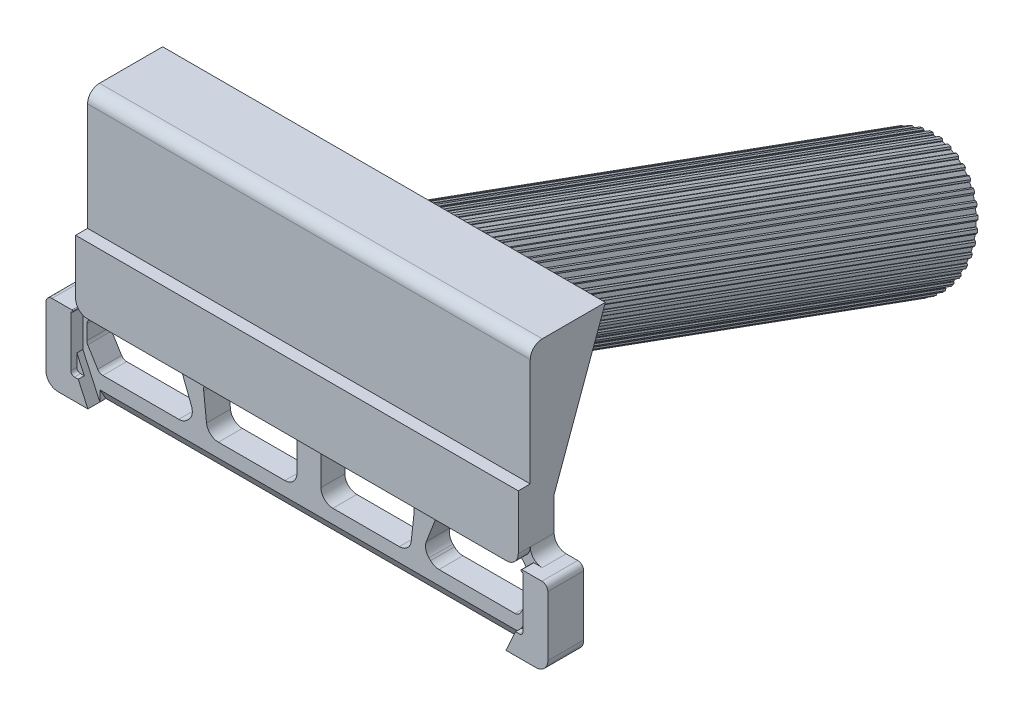
from build123d import *

# Parameters (mm, degrees)
BOSS_EXTRUDE3_DEPTH              = 2
BOSS_EXTRUDE4_DEPTH              = 1
PILL_EXTRUDE_DEPTH               = 1
BOSS_EXTRUDE7_DEPTH              = 1
CUT_EXTRUDE2_DEPTH               = 0.5
BOSS_EXTRUDE11_REACH             = 22.964
BOSS_EXTRUDE11_DIRECTION_2_REACH = 22.964
SKETCH28_R                       = 5
SKETCH28_R_2                     = 2.5
BOSS_EXTRUDE12_DEPTH             = 50
BOSS_EXTRUDE13_DEPTH             = 45
CHAMFER3_SIZE                    = 0.1
CIRPATTERN1_COUNT                = 40
CHAMFER3_OF_CIRPATTERN1_SIZE     = 0.1
CUT_EXTRUDE11_DEPTH              = 17.464143
CUT_EXTRUDE11_DEPTH_BACK         = 17.464143


with BuildPart() as part:
    # base plate → Boss-Extrude3 (new body)
    with BuildSketch(Plane.XY):
        with BuildLine():
            Line((19.493715087, 6.5), (20.464143237, 6.5))
            ThreePointArc((20.464143237, 6.5), (20.817696627, 6.353553391), (20.964143237, 6))
            Line((20.964143237, 6), (20.964143237, 1))
            ThreePointArc((20.964143237, 1), (20.671250018, 0.292893219), (19.964143237, 0))
            Line((19.964143237, 0), (-19.964143237, 0))
            ThreePointArc((-19.964143237, 0), (-20.671250018, 0.292893219), (-20.964143237, 1))
            Line((-20.964143237, 1), (-20.964143237, 6))
            ThreePointArc((-20.964143237, 6), (-20.817696627, 6.353553391), (-20.464143237, 6.5))
            Line((-20.464143237, 6.5), (-19.493715087, 6.5))
            ThreePointArc((-19.493715087, 6.5), (-18.786608306, 6.792893219), (-18.493715087, 7.5))
            Line((-18.493715087, 7.5), (-18.493715087, 12.054490319))
            Line((-18.493715087, 12.054490319), (18.493715087, 12.054490319))
            Line((18.493715087, 12.054490319), (18.493715087, 7.5))
            ThreePointArc((18.493715087, 7.5), (18.786608306, 6.792893219), (19.493715087, 6.5))
        make_face()
        with BuildLine():
            Line((2.006153053, 6.5), (7.956153053, 6.5))
            Line((7.956153053, 6.5), (8.501671849, 5.954481204))
            ThreePointArc((8.501671849, 5.954481204), (8.737625541, 5.579995745), (8.788820951, 5.140345277))
            Line((8.788820951, 5.140345277), (8.55227912, 2.942970854))
            ThreePointArc((8.55227912, 2.942970854), (8.226218887, 2.3060144), (7.558023237, 2.05))
            Line((7.558023237, 2.05), (2.006153053, 2.05))
            ThreePointArc((2.006153053, 2.05), (1.299046272, 2.342893219), (1.006153053, 3.05))
            Line((1.006153053, 3.05), (1.006153053, 5.5))
            ThreePointArc((1.006153053, 5.5), (1.299046272, 6.207106781), (2.006153053, 6.5))
        make_face(mode=Mode.SUBTRACT)
        with BuildLine():
            Line((18.011095885, 6.057365635), (18.465133578, 5.381018621))
            ThreePointArc((18.465133578, 5.381018621), (18.528313072, 5.247995014), (18.55, 5.102335803))
            Line((18.55, 5.102335803), (18.55, 3.895789668))
            ThreePointArc((18.55, 3.895789668), (18.531183389, 3.759912717), (18.476149817, 3.634262741))
            Line((18.476149817, 3.634262741), (17.650242536, 2.288473073))
            ThreePointArc((17.650242536, 2.288473073), (17.468261244, 2.113672449), (17.224092719, 2.05))
            Line((17.224092719, 2.05), (10.870366616, 2.05))
            ThreePointArc((10.870366616, 2.05), (10.487683183, 2.126120467), (10.163259834, 2.342893219))
            Line((10.163259834, 2.342893219), (10.03330995, 2.472843103))
            ThreePointArc((10.03330995, 2.472843103), (9.761890711, 2.973826553), (9.808152704, 3.541728524))
            Line((9.808152704, 3.541728524), (10.708481955, 5.861778639))
            ThreePointArc((10.708481955, 5.861778639), (11.075847159, 6.325160178), (11.640745982, 6.5))
            Line((11.640745982, 6.5), (17.18082873, 6.5))
            ThreePointArc((17.18082873, 6.5), (17.651272332, 6.382430064), (18.011095885, 6.057365635))
        make_face(mode=Mode.SUBTRACT)
        with BuildLine():
            Line((-9.808152704, 3.541728524), (-10.708481955, 5.861778639))
            ThreePointArc((-10.708481955, 5.861778639), (-11.075847159, 6.325160178), (-11.640745982, 6.5))
            Line((-11.640745982, 6.5), (-17.18082873, 6.5))
            ThreePointArc((-17.18082873, 6.5), (-17.651272332, 6.382430064), (-18.011095885, 6.057365635))
            Line((-18.011095885, 6.057365635), (-18.465133578, 5.381018621))
            ThreePointArc((-18.465133578, 5.381018621), (-18.528313072, 5.247995014), (-18.55, 5.102335803))
            Line((-18.55, 5.102335803), (-18.55, 3.895789668))
            ThreePointArc((-18.55, 3.895789668), (-18.531183389, 3.759912717), (-18.476149817, 3.634262741))
            Line((-18.476149817, 3.634262741), (-17.650242536, 2.288473073))
            ThreePointArc((-17.650242536, 2.288473073), (-17.468261244, 2.113672449), (-17.224092719, 2.05))
            Line((-17.224092719, 2.05), (-10.870366616, 2.05))
            ThreePointArc((-10.870366616, 2.05), (-10.487683183, 2.126120467), (-10.163259834, 2.342893219))
            Line((-10.163259834, 2.342893219), (-10.03330995, 2.472843103))
            ThreePointArc((-10.03330995, 2.472843103), (-9.761890711, 2.973826553), (-9.808152704, 3.541728524))
        make_face(mode=Mode.SUBTRACT)
        with BuildLine():
            Line((-8.788820951, 5.140345277), (-8.55227912, 2.942970854))
            ThreePointArc((-8.55227912, 2.942970854), (-8.226218887, 2.3060144), (-7.558023237, 2.05))
            Line((-7.558023237, 2.05), (-2.006153053, 2.05))
            ThreePointArc((-2.006153053, 2.05), (-1.299046272, 2.342893219), (-1.006153053, 3.05))
            Line((-1.006153053, 3.05), (-1.006153053, 5.5))
            ThreePointArc((-1.006153053, 5.5), (-1.299046272, 6.207106781), (-2.006153053, 6.5))
            Line((-2.006153053, 6.5), (-7.956153053, 6.5))
            Line((-7.956153053, 6.5), (-8.501671849, 5.954481204))
            ThreePointArc((-8.501671849, 5.954481204), (-8.737625541, 5.579995745), (-8.788820951, 5.140345277))
        make_face(mode=Mode.SUBTRACT)
    extrude(amount=BOSS_EXTRUDE3_DEPTH)

    # Sketch3 → Boss-Extrude4 (add)
    with BuildSketch(Plane.XY.offset(2)):
        with BuildLine():
            Line((-18.493715087, 12.054490319), (18.493715087, 12.054490319))
            Line((18.493715087, 12.054490319), (18.493715087, 7.5))
            ThreePointArc((18.493715087, 7.5), (18.200821868, 6.792893219), (17.493715087, 6.5))
            Line((17.493715087, 6.5), (-17.493715087, 6.5))
            ThreePointArc((-17.493715087, 6.5), (-18.200821868, 6.792893219), (-18.493715087, 7.5))
            Line((-18.493715087, 7.5), (-18.493715087, 12.054490319))
        make_face()
    extrude(amount=BOSS_EXTRUDE4_DEPTH)

    # pill → pill extrude (add)
    with BuildSketch(Plane.XY.offset(3)):
        with BuildLine():
            Line((18.884533801, 6), (20.964143237, 6))
            ThreePointArc((20.964143237, 6), (20.817696627, 6.353553391), (20.464143237, 6.5))
            Line((20.464143237, 6.5), (18.798100713, 6.5))
            ThreePointArc((18.798100713, 6.5), (18.748603238, 6.479497475), (18.728100713, 6.43))
            Line((18.728100713, 6.43), (18.728100713, 6.409629257))
            ThreePointArc((18.728100713, 6.409629257), (18.748603238, 6.360131783), (18.798100713, 6.339629257))
            Line((18.798100713, 6.339629257), (18.814533801, 6.339629257))
            ThreePointArc((18.814533801, 6.339629257), (18.864031276, 6.319126732), (18.884533801, 6.269629257))
            Line((18.884533801, 6.269629257), (18.884533801, 6))
        make_face()
        with BuildLine():
            Line((-20.964143237, 6), (-18.884533801, 6))
            Line((-18.884533801, 6), (-18.884533801, 6.269629257))
            ThreePointArc((-18.884533801, 6.269629257), (-18.864031276, 6.319126732), (-18.814533801, 6.339629257))
            Line((-18.814533801, 6.339629257), (-18.798100713, 6.339629257))
            ThreePointArc((-18.798100713, 6.339629257), (-18.748603238, 6.360131783), (-18.728100713, 6.409629257))
            Line((-18.728100713, 6.409629257), (-18.728100713, 6.43))
            ThreePointArc((-18.728100713, 6.43), (-18.748603238, 6.479497475), (-18.798100713, 6.5))
            Line((-18.798100713, 6.5), (-20.464143237, 6.5))
            ThreePointArc((-20.464143237, 6.5), (-20.817696627, 6.353553391), (-20.964143237, 6))
        make_face()
    extrude(amount=-PILL_EXTRUDE_DEPTH)

    # pods → Boss-Extrude7 (add)
    with BuildSketch(Plane.XY.offset(2)):
        with BuildLine():
            Line((20.964143237, 1), (20.964143237, 6))
            Line((20.964143237, 6), (18.884533801, 6))
            Line((18.884533801, 6), (18.884533801, 3.1))
            Line((18.884533801, 3.1), (17.464143237, 0))
            Line((17.464143237, 0), (19.964143237, 0))
            ThreePointArc((19.964143237, 0), (20.671250018, 0.292893219), (20.964143237, 1))
        make_face()
        with BuildLine():
            Line((-17.464143237, 0), (-18.884533801, 3.1))
            Line((-18.884533801, 3.1), (-18.884533801, 6))
            Line((-18.884533801, 6), (-20.964143237, 6))
            Line((-20.964143237, 6), (-20.964143237, 1))
            ThreePointArc((-20.964143237, 1), (-20.671250018, 0.292893219), (-19.964143237, 0))
            Line((-19.964143237, 0), (-17.464143237, 0))
        make_face()
    extrude(amount=BOSS_EXTRUDE7_DEPTH)

    # Sketch7 → Cut-Extrude2 (cut)
    with BuildSketch(Plane.XY.offset(3)):
        with BuildLine():
            Line((-18.584533801, 1.75), (18.584533801, 1.75))
            ThreePointArc((18.584533801, 1.75), (18.796665835, 1.837867966), (18.884533801, 2.05))
            Line((18.884533801, 2.05), (18.884533801, 6.269629257))
            Line((18.884533801, 6.269629257), (-18.884533801, 6.269629257))
            Line((-18.884533801, 6.269629257), (-18.884533801, 2.05))
            ThreePointArc((-18.884533801, 2.05), (-18.796665835, 1.837867966), (-18.584533801, 1.75))
        make_face()
    extrude(amount=-CUT_EXTRUDE2_DEPTH, mode=Mode.SUBTRACT)

    # Boss-Extrude11: up to this face of the body (flat: up to its plane)
    boss_extrude11_end = Plane(part.part.faces().sort_by_distance((18.493715087, 9.77724516, 1.5))[0])
    # Sketch12 → Boss-Extrude11 (add, up to the picked face)
    with BuildSketch(Plane(origin=(0, 0, 0), x_dir=(0, 0, -1), z_dir=(1, 0, 0)), mode=Mode.PRIVATE) as boss_extrude11_sk1:
        with BuildLine():
            Line((-2, 12.054490319), (-2, 21.054490319))
            ThreePointArc((-2, 21.054490319), (-1.707106781, 21.7615971), (-1, 22.054490319))
            Line((-1, 22.054490319), (4.275888282, 22.054490319))
            Line((4.275888282, 22.054490319), (0, 10.306583817))
            Line((0, 10.306583817), (-2, 12.054490319))
        make_face()
    boss_extrude11_tool1 = split(extrude(boss_extrude11_sk1.sketch, amount=BOSS_EXTRUDE11_REACH, mode=Mode.PRIVATE), bisect_by=boss_extrude11_end, keep=Keep.BOTH, mode=Mode.PRIVATE)
    add(boss_extrude11_tool1.solids().sort_by_distance((0, 17.406989, -0.321851))[0])

    # Boss-Extrude11 direction 2: up to this face of the body (flat: up to its plane)
    boss_extrude11_direction_2_end = Plane(part.part.faces().sort_by_distance((-18.493715087, 9.77724516, 1.5))[0])
    # Sketch12 → Boss-Extrude11 direction 2 (add, up to the picked face)
    with BuildSketch(Plane(origin=(0, 0, 0), x_dir=(0, 0, -1), z_dir=(1, 0, 0)), mode=Mode.PRIVATE) as boss_extrude11_direction_2_sk1:
        with BuildLine():
            Line((-2, 12.054490319), (-2, 21.054490319))
            ThreePointArc((-2, 21.054490319), (-1.707106781, 21.7615971), (-1, 22.054490319))
            Line((-1, 22.054490319), (4.275888282, 22.054490319))
            Line((4.275888282, 22.054490319), (0, 10.306583817))
            Line((0, 10.306583817), (-2, 12.054490319))
        make_face()
    boss_extrude11_direction_2_tool1 = split(extrude(boss_extrude11_direction_2_sk1.sketch, amount=-BOSS_EXTRUDE11_DIRECTION_2_REACH, mode=Mode.PRIVATE), bisect_by=boss_extrude11_direction_2_end, keep=Keep.BOTH, mode=Mode.PRIVATE)
    add(boss_extrude11_direction_2_tool1.solids().sort_by_distance((0, 17.406989, -0.321851))[0])

    # Sketch28 → Boss-Extrude12 (add)
    with BuildSketch(Plane(origin=(0, 1.205641278, 3.312472188), x_dir=(-1, 0, 0), z_dir=(0, -0.342020143, -0.939692621))):
        with Locations((0, 14)):
            Circle(SKETCH28_R)
        with Locations((0, 14)):
            Circle(SKETCH28_R_2, mode=Mode.SUBTRACT)
    extrude(amount=BOSS_EXTRUDE12_DEPTH)

    # Sketch30 → Boss-Extrude13 (add)
    with BuildSketch(Plane(origin=(0, -15.895365888, -43.672158852), x_dir=(-1, 0, 0), z_dir=(0, -0.342020143, -0.939692621))):
        with BuildLine():
            ThreePointArc((5, 14), (4.995241108, 13.781903063), (4.98097349, 13.564221286))
            Line((4.98097349, 13.564221286), (5.130402695, 13.551147925))
            ThreePointArc((5.130402695, 13.551147925), (5.145098341, 13.775360155), (5.15, 14))
            Line((5.15, 14), (5, 14))
        make_face()
    boss_extrude13 = extrude(amount=-BOSS_EXTRUDE13_DEPTH)

    # Chamfer3
    chamfer3_edges = [part.edges().sort_by_distance(p)[0] for p in [
        (-5.130402695, 4.534001045, -27.163840439),
        (-5.15, 4.955784028, -27.31735689),
    ]]
    chamfer(chamfer3_edges, length=CHAMFER3_SIZE)

    # CirPattern1: Boss-Extrude13 ×40 about axis
    cirpattern1_axis = Axis((0, 13.155696691, -4.788282007), (0, -0.342020143, -0.939692621))
    for i in range(1, CIRPATTERN1_COUNT):
        add(boss_extrude13.rotate(cirpattern1_axis, i * 360 / CIRPATTERN1_COUNT))

    # Chamfer3 of CirPattern1
    chamfer3_of_cirpattern1_edges = [part.edges().sort_by_distance(p)[0] for p in [
        (-5.137454859, 5.293364692, -27.440226204),
        (-5.086594954, 5.712835637, -27.592901142),
        (-5.018005834, 6.044415984, -27.713586518),
        (-4.897941059, 6.451246123, -27.861660579),
        (-4.774996851, 6.768661543, -27.977190344),
        (-4.5886836, 7.152833369, -28.117017454),
        (-4.414411599, 7.448268042, -28.224546881),
        (-4.166437521, 7.800321968, -28.352684031),
        (-3.945128882, 8.066501312, -28.449565389),
        (-3.641599923, 8.377768603, -28.562857418),
        (-3.378703999, 8.608138398, -28.646705166),
        (-3.027094049, 8.870954621, -28.742362449),
        (-2.729084211, 9.059842399, -28.811111977),
        (-2.338051074, 9.267736145, -28.886779113),
        (-2.012265312, 9.410490861, -28.93873758),
        (-1.591437521, 9.558343098, -28.992551393),
        (-1.245897762, 9.651449658, -29.02643941),
        (-0.805637495, 9.735619771, -29.057074826),
        (-0.448852075, 9.776785582, -29.072057956),
        (0, 9.795201025, -29.078760629),
        (0.35924584, 9.783412448, -29.074469938),
        (0.805637495, 9.735619771, -29.057074826),
        (1.15849793, 9.671167081, -29.033615965),
        (1.591437521, 9.558343098, -28.992551393),
        (1.929223956, 9.442813333, -28.950501998),
        (2.338051074, 9.267736145, -28.886779113),
        (2.652446086, 9.103974032, -28.827174578),
        (3.027094049, 8.870954621, -28.742362449),
        (3.31035619, 8.662992526, -28.666670436),
        (3.641599923, 8.377768603, -28.562857418),
        (3.886754338, 8.130727244, -28.472941717),
        (4.166437521, 7.800321968, -28.352684031),
        (4.367447695, 7.520284322, -28.250758663),
        (4.5886836, 7.152833369, -28.117017454),
        (4.740599995, 6.846694892, -28.005592161),
        (4.897941059, 6.451246123, -27.861660579),
        (4.99702299, 6.126544961, -27.743479022),
        (5.086594954, 5.712835637, -27.592901142),
        (5.130402695, 5.377567011, -27.470873342),
        (5.15, 4.955784028, -27.31735689),
        (5.137454859, 4.618203363, -27.194487577),
        (5.086594954, 4.198732419, -27.041812639),
        (5.018005834, 3.867152072, -26.921127262),
        (4.897941059, 3.460321933, -26.773053201),
        (4.774996851, 3.142906512, -26.657523436),
        (4.5886836, 2.758734687, -26.517696327),
        (4.414411599, 2.463300014, -26.4101669),
        (4.166437521, 2.111246087, -26.28202975),
        (3.945128882, 1.845066744, -26.185148392),
        (3.641599923, 1.533799452, -26.071856363),
        (3.378703999, 1.303429657, -25.988008615),
        (3.027094049, 1.040613434, -25.892351332),
        (2.729084211, 0.851725657, -25.823601804),
        (2.338051074, 0.64383191, -25.747934668),
        (2.012265312, 0.501077194, -25.695976201),
        (1.591437521, 0.353224958, -25.642162387),
        (1.245897762, 0.260118398, -25.608274371),
        (0.805637495, 0.175948284, -25.577638955),
        (0.448852075, 0.134782473, -25.562655825),
        (0, 0.116367031, -25.555953152),
        (-0.35924584, 0.128155607, -25.560243843),
        (-0.805637495, 0.175948284, -25.577638955),
        (-1.15849793, 0.240400975, -25.601097816),
        (-1.591437521, 0.353224958, -25.642162387),
        (-1.929223956, 0.468754723, -25.684211783),
        (-2.338051074, 0.64383191, -25.747934668),
        (-2.652446086, 0.807594023, -25.807539203),
        (-3.027094049, 1.040613434, -25.892351332),
        (-3.31035619, 1.248575529, -25.968043345),
        (-3.641599923, 1.533799452, -26.071856363),
        (-3.886754338, 1.780840812, -26.161772064),
        (-4.166437521, 2.111246087, -26.28202975),
        (-4.367447695, 2.391283733, -26.383955118),
        (-4.5886836, 2.758734687, -26.517696327),
        (-4.740599995, 3.064873163, -26.62912162),
        (-4.897941059, 3.460321933, -26.773053201),
        (-4.99702299, 3.785023094, -26.891234759),
        (-5.086594954, 4.198732419, -27.041812639),
    ]]
    chamfer(chamfer3_of_cirpattern1_edges, length=CHAMFER3_OF_CIRPATTERN1_SIZE)

    # Sketch31 → Cut-Extrude11 (cut, two sides)
    with BuildSketch(Plane(origin=(0, 0, 0), x_dir=(0, 0, -1), z_dir=(1, 0, 0))) as cut_extrude11_sk:
        Polygon((-2.5, 1.75), (-0.859497261, -1.091434094), (-4.263515052, -1.091434094), (-4.263515052, 1.75), align=None)
    extrude(amount=CUT_EXTRUDE11_DEPTH, mode=Mode.SUBTRACT)
    extrude(cut_extrude11_sk.sketch, amount=-CUT_EXTRUDE11_DEPTH_BACK, mode=Mode.SUBTRACT)


solid = part.part
